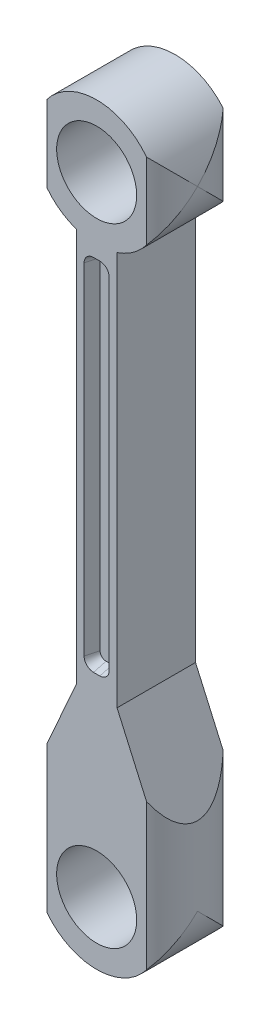
from build123d import *

# Parameters (mm, degrees)
SKETCH1_R               = 6.477
BOSS_EXTRUDE2_DEPTH     = 12.7
CUT_EXTRUDE2_DEPTH      = 2.032
CUT_EXTRUDE2_TAPER      = 15
SKETCH4_OUTSIDE_W       = 47.17
SKETCH4_OUTSIDE_H       = 39.55
SKETCH4_OUTSIDE_R       = 10.16
CUT_EXTRUDE1_DEPTH      = 112.76
CUT_EXTRUDE1_DEPTH_BACK = 11.16


with BuildPart() as part:
    # Sketch1 → Boss-Extrude2 (new body)
    with BuildSketch(Plane.XY):
        with BuildLine():
            Line((-10.16, 0), (-10.16, 12.7))
            Line((-10.16, 12.7), (-3.302, 28.175956627))
            Line((-3.302, 28.175956627), (-3.302, 91.991545598))
            ThreePointArc((-3.302, 91.991545598), (0, 111.76), (3.302, 91.991545598))
            Line((3.302, 91.991545598), (3.302, 28.175956627))
            Line((3.302, 28.175956627), (10.16, 12.7))
            Line((10.16, 12.7), (10.16, 0))
            ThreePointArc((10.16, 0), (0, -10.16), (-10.16, 0))
        make_face()
        Circle(SKETCH1_R, mode=Mode.SUBTRACT)
        with Locations((0, 101.6)):
            Circle(SKETCH1_R, mode=Mode.SUBTRACT)
    extrude(amount=-BOSS_EXTRUDE2_DEPTH)

    # Sketch3 → Cut-Extrude2 (cut)
    with BuildSketch(Plane.XY):
        with BuildLine():
            ThreePointArc((-0.508, 89.408), (-1.585630735, 88.961630735), (-2.032, 87.884))
            Line((-2.032, 87.884), (-2.032, 32.766))
            ThreePointArc((-2.032, 32.766), (-1.585630735, 31.688369265), (-0.508, 31.242))
            Line((-0.508, 31.242), (0.508, 31.242))
            ThreePointArc((0.508, 31.242), (1.585630735, 31.688369265), (2.032, 32.766))
            Line((2.032, 32.766), (2.032, 87.884))
            ThreePointArc((2.032, 87.884), (1.585630735, 88.961630735), (0.508, 89.408))
            Line((0.508, 89.408), (-0.508, 89.408))
        make_face()
    cut_extrude2 = extrude(amount=-CUT_EXTRUDE2_DEPTH, taper=CUT_EXTRUDE2_TAPER, mode=Mode.SUBTRACT)

    # Mirror1: Cut-Extrude2 across plane
    add(cut_extrude2.mirror(Plane.XY.offset(-6.35)), mode=Mode.SUBTRACT)

    # Sketch4 outside → Cut-Extrude1 (cut, two sides)
    with BuildSketch(Plane(origin=(0, 0, 0), x_dir=(1, 0, 0), z_dir=(0, 1, 0))) as cut_extrude1_sk:
        with Locations((0, 6.35)):
            Rectangle(SKETCH4_OUTSIDE_W, SKETCH4_OUTSIDE_H)
        with Locations((0, 6.16880724)):
            Circle(SKETCH4_OUTSIDE_R, mode=Mode.SUBTRACT)
    extrude(amount=CUT_EXTRUDE1_DEPTH, mode=Mode.SUBTRACT)
    extrude(cut_extrude1_sk.sketch, amount=-CUT_EXTRUDE1_DEPTH_BACK, mode=Mode.SUBTRACT)


solid = part.part
